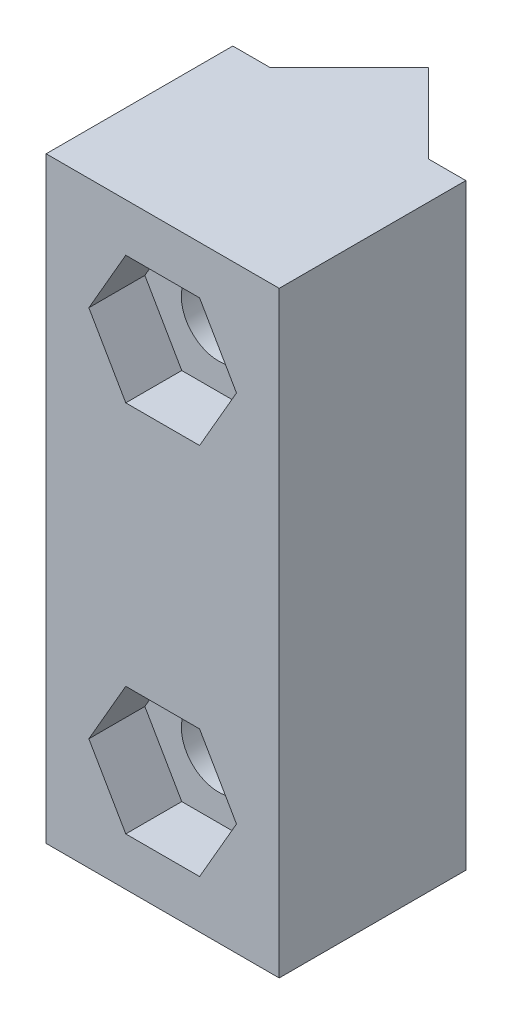
from build123d import *

# Parameters (mm, degrees)
BOSS_EXTRUDE1_DEPTH      = 25
BOSS_EXTRUDE1_DEPTH_BACK = 7
SKETCH3_R                = 2
CUT_EXTRUDE1_DEPTH       = 25
CUT_EXTRUDE2_DEPTH       = 3


with BuildPart() as part:
    # Sketch2 → Boss-Extrude1 (new body, two sides)
    with BuildSketch(Plane(origin=(0, 0, 0), x_dir=(1, 0, 0), z_dir=(0, 1, 0))) as boss_extrude1_sk:
        Polygon((-4.989079304, 0), (-2.989079304, 0), (1.253561383, 4.242640687), (5.49620207, 0), (7.49620207, 0), (7.49620207, -10), (-4.989079304, -10), align=None)
    extrude(amount=BOSS_EXTRUDE1_DEPTH)
    extrude(boss_extrude1_sk.sketch, amount=-BOSS_EXTRUDE1_DEPTH_BACK)

    # Sketch3 → Cut-Extrude1 (cut)
    with BuildSketch(Plane.XY.offset(10)):
        with Locations((1.253561383, 19)):
            Circle(SKETCH3_R)
        with Locations((1.253561383, -1)):
            Circle(SKETCH3_R)
    extrude(amount=-CUT_EXTRUDE1_DEPTH, mode=Mode.SUBTRACT)

    # Sketch4 → Cut-Extrude2 (cut)
    with BuildSketch(Plane.XY.offset(10)):
        Polygon((5.208410727, -1), (3.230986055, 2.425), (-0.723863289, 2.425), (-2.701287961, -1), (-0.723863289, -4.425), (3.230986055, -4.425), align=None)
        Polygon((3.230986055, 22.425), (5.208410727, 19), (3.230986055, 15.575), (-0.723863289, 15.575), (-2.701287961, 19), (-0.723863289, 22.425), align=None)
    extrude(amount=-CUT_EXTRUDE2_DEPTH, mode=Mode.SUBTRACT)


solid = part.part
